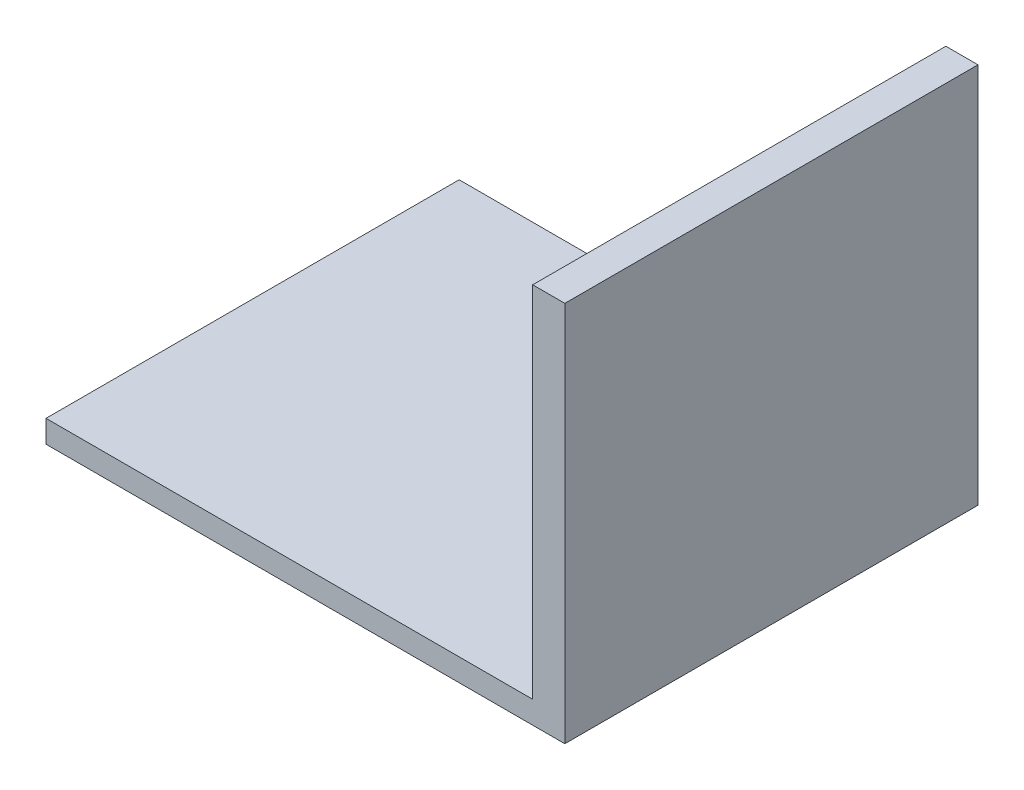
from build123d import *

# Parameters (mm, degrees)
SKETCH1_W           = 92.495530799
SKETCH1_H           = 73.66
BOSS_EXTRUDE1_DEPTH = 4
SKETCH2_W           = 5.728735407
SKETCH2_H           = 73.66
BOSS_EXTRUDE2_DEPTH = 64


with BuildPart() as part:
    # Sketch1 → Boss-Extrude1 (new body)
    with BuildSketch(Plane(origin=(0, 0, 0), x_dir=(1, 0, 0), z_dir=(0, 1, 0))):
        with Locations((5.915411854, -2.157941762)):
            Rectangle(SKETCH1_W, SKETCH1_H)
    extrude(amount=BOSS_EXTRUDE1_DEPTH)

    # Sketch2 → Boss-Extrude2 (add)
    with BuildSketch(Plane(origin=(0, 4, 0), x_dir=(1, 0, 0), z_dir=(0, 1, 0))):
        with Locations((49.29880955, -2.157941762)):
            Rectangle(SKETCH2_W, SKETCH2_H)
    extrude(amount=BOSS_EXTRUDE2_DEPTH)


solid = part.part
